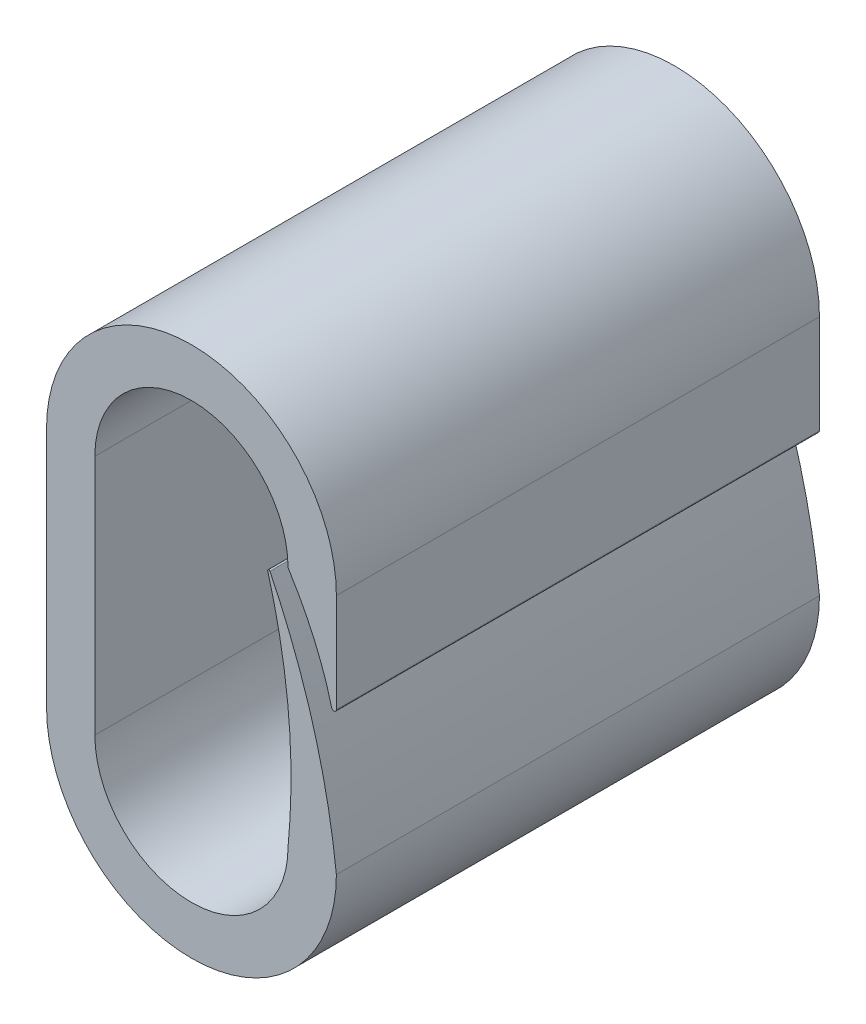
from build123d import *

# Parameters (mm, degrees)
BOSS_EXTRUDE1_DEPTH = 10
FILLET1_R           = 0.025
FILLET2_R           = 0.05


with BuildPart() as part:
    # Sketch1 → Boss-Extrude1 (new body)
    with BuildSketch(Plane.XY):
        with BuildLine():
            ThreePointArc((2, -2.5), (0, -4.5), (-2, -2.5))
            Line((-2, -2.5), (-2, 2.5))
            ThreePointArc((-2, 2.5), (0, 4.5), (2, 2.5))
            add(Edge.make_bspline(
                [(2, 2.5), (2.759271996, 1.299931224), (3, 0)],
                knots=[0, 0, 0, 0.518543991, 0.518543991, 0.518543991], degree=2))
            Line((3, 0), (3, 2.5))
            ThreePointArc((3, 2.5), (0, 5.5), (-3, 2.5))
            Line((-3, 2.5), (-3, -2.5))
            ThreePointArc((-3, -2.5), (0, -5.5), (3, -2.5))
            add(Edge.make_bspline(
                [(3, -2.5), (2.709402649, 0.136566945), (1.5, 2.5)],
                knots=[0, 0, 0, 1, 1, 1], degree=2))
            add(Edge.make_bspline(
                [(2, -2.5), (2.245145169, 0.049029034), (1.5, 2.5)],
                knots=[0, 0, 0, 1, 1, 1], degree=2))
        make_face()
    extrude(amount=BOSS_EXTRUDE1_DEPTH)

    # Fillet1
    fillet1_edges = [part.edges().sort_by_distance(p)[0] for p in [
        (1.5, 2.5, 5),
    ]]
    fillet(fillet1_edges, radius=FILLET1_R)

    # Fillet2
    fillet2_edges = [part.edges().sort_by_distance(p)[0] for p in [
        (3, 0, 5),
    ]]
    fillet(fillet2_edges, radius=FILLET2_R)


solid = part.part
